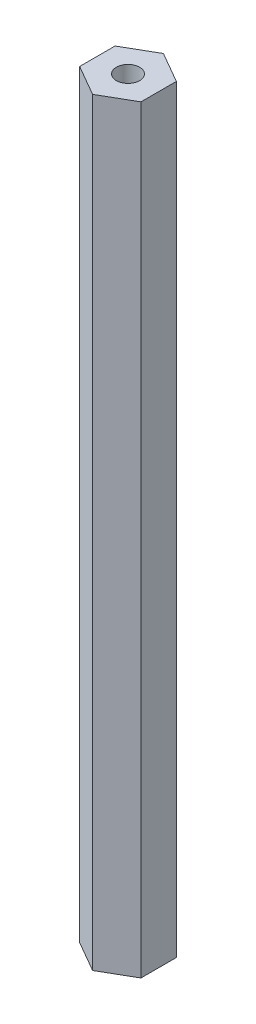
from build123d import *

# Parameters (mm, degrees)
BOSS_EXTRUDE1_DEPTH                        = 157.1625
F_10_32_TAPPED_HOLE1_D                     = 4.0386
F_10_32_TAPPED_HOLE1_DEPTH                 = 16.764
F_10_32_TAPPED_HOLE1_CBORE_D               = 4.826
F_10_32_TAPPED_HOLE1_CBORE_DEPTH           = 12.7
F_10_32_TAPPED_HOLE1_TIP                   = 1.213317848
F_10_32_TAPPED_HOLE1_ON_FACE_2_D           = 4.0386
F_10_32_TAPPED_HOLE1_ON_FACE_2_DEPTH       = 16.764
F_10_32_TAPPED_HOLE1_ON_FACE_2_CBORE_D     = 4.826
F_10_32_TAPPED_HOLE1_ON_FACE_2_CBORE_DEPTH = 12.7
F_10_32_TAPPED_HOLE1_ON_FACE_2_TIP         = 1.213317848


with BuildPart() as part:
    # Sketch1 → Boss-Extrude1 (new body)
    with BuildSketch(Plane(origin=(0, 0, 0), x_dir=(1, 0, 0), z_dir=(0, 1, 0))):
        Polygon((0, 7.332348419), (-6.35, 3.666174209), (-6.35, -3.666174209), (0, -7.332348419), (6.35, -3.666174209), (6.35, 3.666174209), align=None)
    extrude(amount=BOSS_EXTRUDE1_DEPTH)

    # #10-32 Tapped Hole1
    with Locations(Plane.ZX.offset(157.1625)):
        with Locations((0, 0)):
            CounterBoreHole(F_10_32_TAPPED_HOLE1_D / 2, F_10_32_TAPPED_HOLE1_CBORE_D / 2, F_10_32_TAPPED_HOLE1_CBORE_DEPTH, depth=F_10_32_TAPPED_HOLE1_DEPTH)
            with Locations((0, 0, -(F_10_32_TAPPED_HOLE1_DEPTH + F_10_32_TAPPED_HOLE1_TIP / 2))):  # 118° drill point
                Cone(0, F_10_32_TAPPED_HOLE1_D / 2, F_10_32_TAPPED_HOLE1_TIP, mode=Mode.SUBTRACT)

    # #10-32 Tapped Hole1 on face 2
    with Locations(Plane(origin=(0, 0, 0), x_dir=(0, 0, -1), z_dir=(0, -1, 0))):
        with Locations((0, 0)):
            CounterBoreHole(F_10_32_TAPPED_HOLE1_ON_FACE_2_D / 2, F_10_32_TAPPED_HOLE1_ON_FACE_2_CBORE_D / 2, F_10_32_TAPPED_HOLE1_ON_FACE_2_CBORE_DEPTH, depth=F_10_32_TAPPED_HOLE1_ON_FACE_2_DEPTH)
            with Locations((0, 0, -(F_10_32_TAPPED_HOLE1_ON_FACE_2_DEPTH + F_10_32_TAPPED_HOLE1_ON_FACE_2_TIP / 2))):  # 118° drill point
                Cone(0, F_10_32_TAPPED_HOLE1_ON_FACE_2_D / 2, F_10_32_TAPPED_HOLE1_ON_FACE_2_TIP, mode=Mode.SUBTRACT)


solid = part.part
